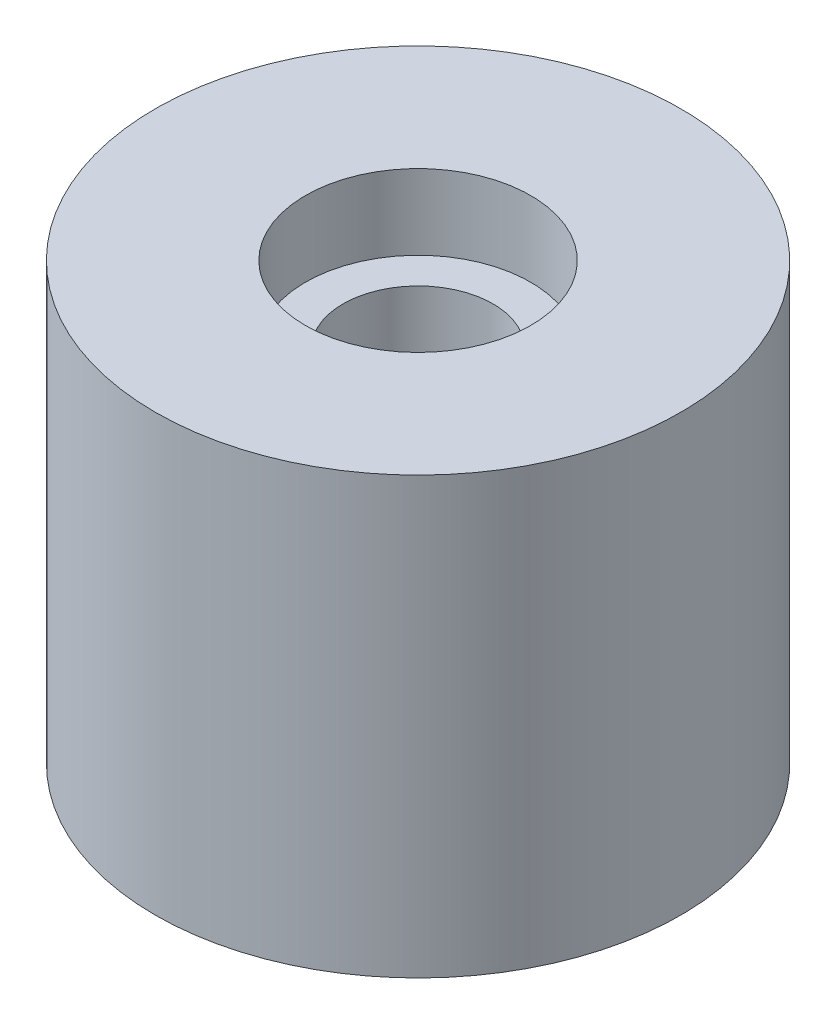
from build123d import *


with BuildPart() as part:
    # Sketch1 → Revolve1 (revolve)
    with BuildSketch(Plane.XY):
        Polygon((7.5, 15.047486034), (7.5, 10.047486034), (5, 10.047486034), (5, -8.952513966), (7.5, -8.952513966), (7.5, -13.952513966), (17.5, -13.952513966), (17.5, 15.047486034), align=None)
    revolve(axis=Axis((0, 16.047486034, 0), (0, -1, 0)))


solid = part.part
